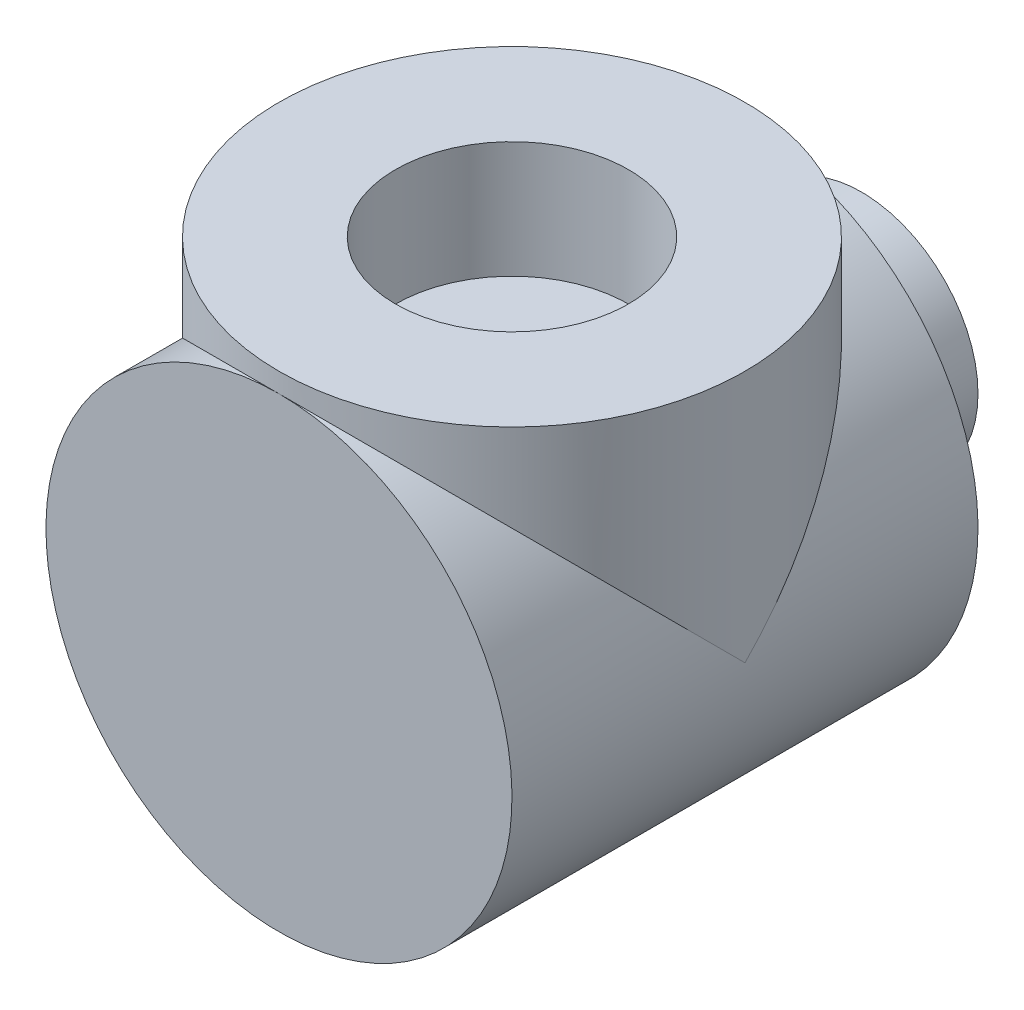
from build123d import *
from build123d.topology import SkipClean

# Parameters (mm, degrees)
SKETCH1_R           = 30
SKETCH1_R_2         = 15
BOSS_EXTRUDE1_DEPTH = 30
SKETCH2_R           = 30
SKETCH2_R_2         = 15
BOSS_EXTRUDE2_DEPTH = 32.5
CUT_EXTRUDE2_START  = 32.5
SKETCH2_3_R         = 15
CUT_EXTRUDE2_DEPTH  = 15
BOSS_EXTRUDE3_START = -30
SKETCH1_4_R         = 15
BOSS_EXTRUDE3_DEPTH = 15


with BuildPart() as part:
    # Sketch1 → Boss-Extrude1 (new, symmetric)
    with BuildSketch(Plane.XY):
        Circle(SKETCH1_R)
        Circle(SKETCH1_R_2, mode=Mode.SUBTRACT)
        Circle(SKETCH1_R_2)
    extrude(amount=BOSS_EXTRUDE1_DEPTH, both=True)

    # Sketch2 → Boss-Extrude2 (add)
    with SkipClean():  # the faces are left unmerged after this step: merging them gives an invalid solid
        with BuildSketch(Plane(origin=(0, 0, 0), x_dir=(1, 0, 0), z_dir=(0, 1, 0))):
            with Locations(Location((0, 0, 0), (0, 0, 270))):
                Circle(SKETCH2_R)
            Circle(SKETCH2_R_2, mode=Mode.SUBTRACT)
            Circle(SKETCH2_R_2)
        extrude(amount=BOSS_EXTRUDE2_DEPTH)

    # Sketch2_3 → Cut-Extrude2 (cut)
    with SkipClean():  # the faces are left unmerged after this step: merging them gives an invalid solid
        with BuildSketch(Plane(origin=(0, 0, 0), x_dir=(1, 0, 0), z_dir=(0, 1, 0)).offset(CUT_EXTRUDE2_START)):
            with Locations(Location((0, 0, 0), (0, 0, 270))):
                Circle(SKETCH2_3_R)
        extrude(amount=-CUT_EXTRUDE2_DEPTH, mode=Mode.SUBTRACT)

    # Sketch1_4 → Boss-Extrude3 (add)
    with SkipClean():  # the faces are left unmerged after this step: merging them gives an invalid solid
        with BuildSketch(Plane.XY.offset(BOSS_EXTRUDE3_START)):
            Circle(SKETCH1_4_R)
        extrude(amount=-BOSS_EXTRUDE3_DEPTH)


solid = part.part
